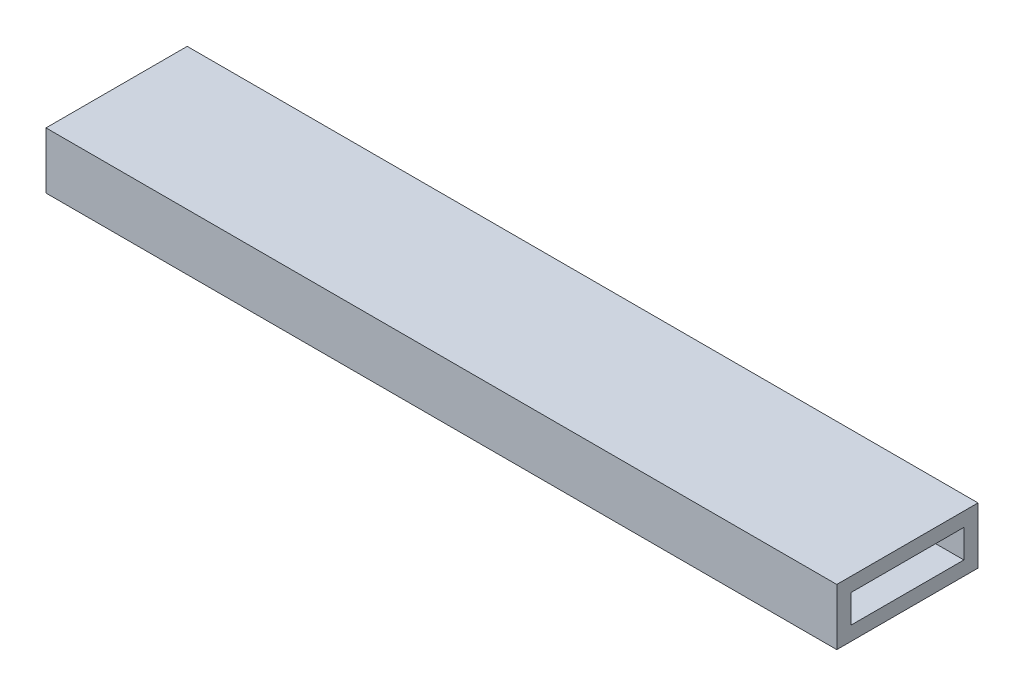
from build123d import *

# Parameters (mm, degrees)
SKETCH1_W           = 100
SKETCH1_H           = 40
SKETCH1_W_2         = 80
SKETCH1_H_2         = 20
BOSS_EXTRUDE1_DEPTH = 560


with BuildPart() as part:
    # Sketch1 → Boss-Extrude1 (new body)
    with BuildSketch(Plane(origin=(0, 0, 0), x_dir=(0, 0, -1), z_dir=(1, 0, 0))):
        with Locations((50, 20)):
            Rectangle(SKETCH1_W, SKETCH1_H)
        with Locations((50, 20)):
            Rectangle(SKETCH1_W_2, SKETCH1_H_2, mode=Mode.SUBTRACT)
    extrude(amount=BOSS_EXTRUDE1_DEPTH)


solid = part.part
